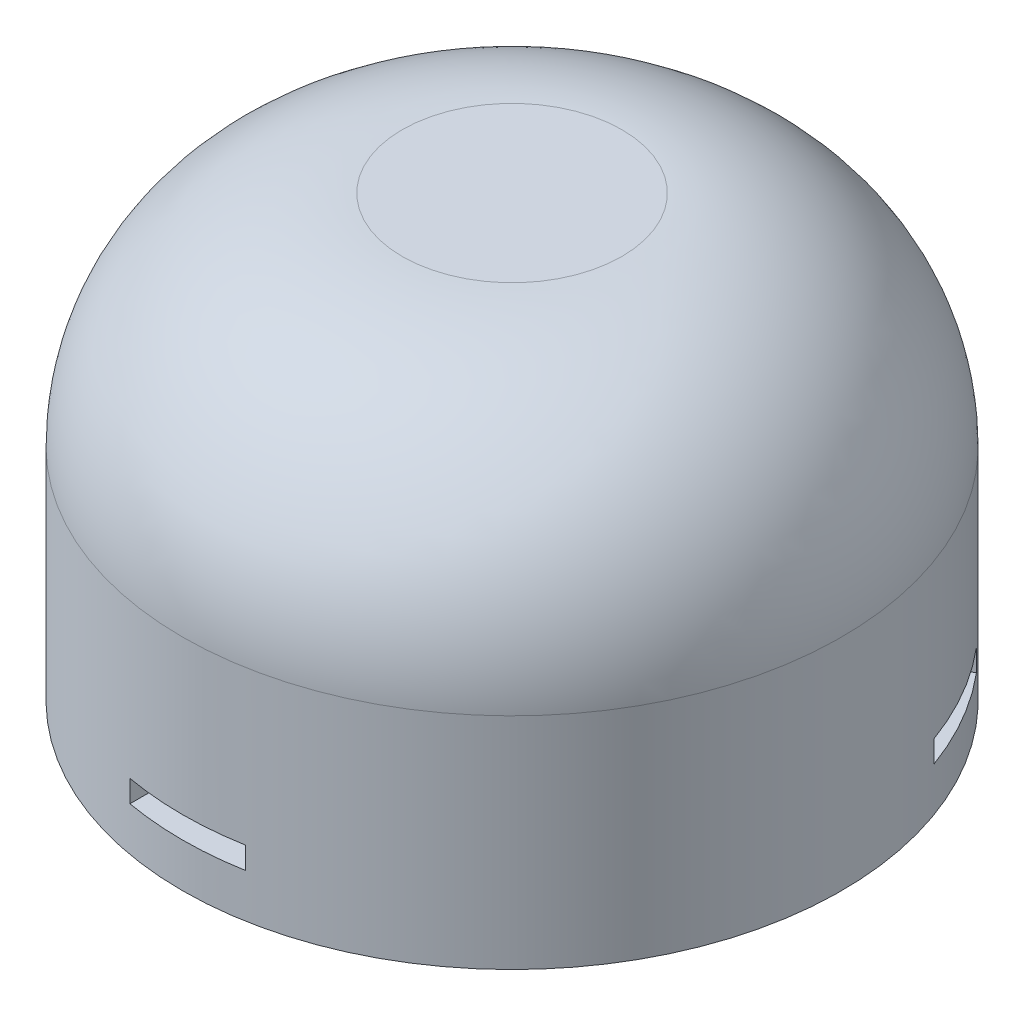
from build123d import *

# Parameters (mm, degrees)
SKETCH1_R           = 15
BOSS_EXTRUDE1_DEPTH = 20
FILLET1_R           = 10
CUT_EXTRUDE1_START  = 40
SKETCH2_W           = 5.25
SKETCH2_H           = 1
CUT_EXTRUDE1_DEPTH  = 30
CIRPATTERN1_COUNT   = 3


with BuildPart() as part:
    # Sketch1 → Boss-Extrude1 (new body)
    with BuildSketch(Plane(origin=(0, 0, 0), x_dir=(1, 0, 0), z_dir=(0, 1, 0))):
        Circle(SKETCH1_R)
    extrude(amount=BOSS_EXTRUDE1_DEPTH)

    # Fillet1
    fillet1_edges = [part.edges().sort_by_distance(p)[0] for p in [
        (-15, 20, 0),
    ]]
    fillet(fillet1_edges, radius=FILLET1_R)

    # Sketch2 → Cut-Extrude1 (cut)
    with BuildSketch(Plane.XY.offset(CUT_EXTRUDE1_START)):
        with Locations((0, 2.5)):
            Rectangle(SKETCH2_W, SKETCH2_H)
    cut_extrude1 = extrude(amount=-CUT_EXTRUDE1_DEPTH, mode=Mode.SUBTRACT)

    # CirPattern1: Cut-Extrude1 ×3 about axis
    cirpattern1_axis = Axis((0, 0, 0), (0, 1, 0))
    for i in range(1, CIRPATTERN1_COUNT):
        add(cut_extrude1.rotate(cirpattern1_axis, i * 360 / CIRPATTERN1_COUNT), mode=Mode.SUBTRACT)


solid = part.part
